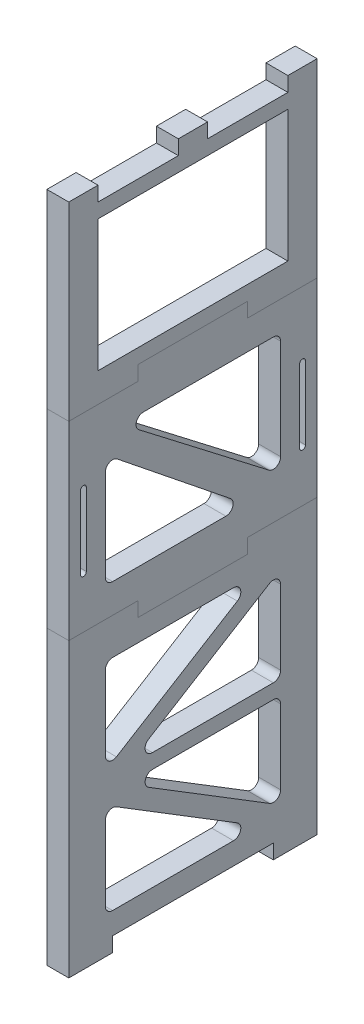
from build123d import *

# Parameters (mm, degrees)
SKETCH1_W                = 170
SKETCH1_H                = 410
BOSS_EXTRUDE1_DEPTH      = 15
SKETCH11_W               = 15
SKETCH11_H               = 30
BOSS_EXTRUDE8_DEPTH      = 10
SKETCH14_W               = 15
SKETCH14_H               = 170
BOSS_EXTRUDE9_DEPTH      = 30
SKETCH15_W               = 15
SKETCH15_H               = 20
BOSS_EXTRUDE10_DEPTH     = 10
SKETCH16_W               = 15
SKETCH16_H               = 20
BOSS_EXTRUDE11_DEPTH     = 10
CUT_EXTRUDE1_DEPTH       = 15
SKETCH25_W               = 130
SKETCH25_H               = 90
CUT_EXTRUDE3_DEPTH       = 15
CUT_EXTRUDE4_DEPTH       = 15
CUT_EXTRUDE5_DEPTH       = 15
SPLIT2_SURFACE_1_1_BACK  = 491.637
SPLIT2_SURFACE_1_1_DEPTH = 983.274
SPLIT2_SURFACE_1_2_BACK  = 491.637
SPLIT2_SURFACE_1_2_DEPTH = 983.274
SPLIT2_SURFACE_2_3_BACK  = 491.637
SPLIT2_SURFACE_2_3_DEPTH = 983.274
SPLIT2_SURFACE_2_4_BACK  = 491.637
SPLIT2_SURFACE_2_4_DEPTH = 983.274


with BuildPart() as part:
    # Sketch1 → Boss-Extrude1 (new body)
    with BuildSketch(Plane(origin=(0, 0, 0), x_dir=(0, 0, -1), z_dir=(1, 0, 0))):
        with Locations((85, 205)):
            Rectangle(SKETCH1_W, SKETCH1_H)
    extrude(amount=BOSS_EXTRUDE1_DEPTH)

    # Sketch11 → Boss-Extrude8 (add)
    with BuildSketch(Plane.XZ):
        with Locations((7.5, -15)):
            Rectangle(SKETCH11_W, SKETCH11_H)
        with Locations((7.5, -155)):
            Rectangle(SKETCH11_W, SKETCH11_H)
    extrude(amount=BOSS_EXTRUDE8_DEPTH)

    # Sketch14 → Boss-Extrude9 (add)
    with BuildSketch(Plane(origin=(0, 410, 0), x_dir=(1, 0, 0), z_dir=(0, 1, 0))):
        with Locations((7.5, 85)):
            Rectangle(SKETCH14_W, SKETCH14_H)
    extrude(amount=BOSS_EXTRUDE9_DEPTH)

    # Sketch15 → Boss-Extrude10 (add)
    with BuildSketch(Plane(origin=(0, 440, 0), x_dir=(1, 0, 0), z_dir=(0, 1, 0))):
        with Locations((7.5, 160)):
            Rectangle(SKETCH15_W, SKETCH15_H)
    boss_extrude10 = extrude(amount=BOSS_EXTRUDE10_DEPTH)

    # Mirror1: Boss-Extrude10 across plane
    add(boss_extrude10.mirror(Plane.XY.offset(-85)))

    # Sketch16 → Boss-Extrude11 (add)
    with BuildSketch(Plane(origin=(0, 440, 0), x_dir=(1, 0, 0), z_dir=(0, 1, 0))):
        with Locations((7.5, 85)):
            Rectangle(SKETCH16_W, SKETCH16_H)
    extrude(amount=BOSS_EXTRUDE11_DEPTH)

    # Sketch21 → Cut-Extrude1 (cut)
    with BuildSketch(Plane(origin=(15, 0, 0), x_dir=(0, 0, -1), z_dir=(1, 0, 0))):
        with BuildLine():
            Line((12, 275), (12, 225))
            ThreePointArc((12, 225), (10, 223), (8, 225))
            Line((8, 225), (8, 275))
            ThreePointArc((8, 275), (10, 277), (12, 275))
        make_face()
    cut_extrude1 = extrude(amount=-CUT_EXTRUDE1_DEPTH, mode=Mode.SUBTRACT)

    # Mirror3: Cut-Extrude1 across plane
    add(cut_extrude1.mirror(Plane.XY.offset(-85)), mode=Mode.SUBTRACT)

    # Sketch25 → Cut-Extrude3 (cut)
    with BuildSketch(Plane(origin=(15, 0, 0), x_dir=(0, 0, -1), z_dir=(1, 0, 0))):
        with Locations((85, 385)):
            Rectangle(SKETCH25_W, SKETCH25_H)
    extrude(amount=-CUT_EXTRUDE3_DEPTH, mode=Mode.SUBTRACT)

    # Sketch26 → Cut-Extrude4 (cut)
    with BuildSketch(Plane(origin=(15, 0, 0), x_dir=(0, 0, -1), z_dir=(1, 0, 0))):
        with BuildLine():
            Line((25, 70.930175943), (25, 20))
            ThreePointArc((25, 20), (26.464466094, 16.464466094), (30, 15))
            Line((30, 15), (112.761535907, 15))
            ThreePointArc((112.761535907, 15), (117.572536734, 18.638283788), (115.382023035, 24.258291584))
            Line((115.382023035, 24.258291584), (32.620487128, 75.188467526))
            ThreePointArc((32.620487128, 75.188467526), (27.560987458, 75.294946019), (25, 70.930175943))
        make_face()
        with BuildLine():
            Line((54.617976965, 75.741708416), (137.379512872, 24.811532474))
            ThreePointArc((137.379512872, 24.811532474), (142.439012542, 24.705053981), (145, 29.069824057))
            Line((145, 29.069824057), (145, 80))
            ThreePointArc((145, 80), (143.535533906, 83.535533906), (140, 85))
            Line((140, 85), (57.238464093, 85))
            ThreePointArc((57.238464093, 85), (52.427463266, 81.361716212), (54.617976965, 75.741708416))
        make_face()
        with BuildLine():
            Line((54.617976965, 104.258291584), (137.379512872, 155.188467526))
            ThreePointArc((137.379512872, 155.188467526), (142.439012542, 155.294946019), (145, 150.930175943))
            Line((145, 150.930175943), (145, 100))
            ThreePointArc((145, 100), (143.535533906, 96.464466094), (140, 95))
            Line((140, 95), (57.238464093, 95))
            ThreePointArc((57.238464093, 95), (52.427463266, 98.638283788), (54.617976965, 104.258291584))
        make_face()
        with BuildLine():
            Line((25, 160), (25, 109.069824057))
            ThreePointArc((25, 109.069824057), (27.560987458, 104.705053981), (32.620487128, 104.811532474))
            Line((32.620487128, 104.811532474), (115.382023035, 155.741708416))
            ThreePointArc((115.382023035, 155.741708416), (117.572536734, 161.361716212), (112.761535907, 165))
            Line((112.761535907, 165), (30, 165))
            ThreePointArc((30, 165), (26.464466094, 163.535533906), (25, 160))
        make_face()
    extrude(amount=-CUT_EXTRUDE4_DEPTH, mode=Mode.SUBTRACT)

    # Sketch24 → Cut-Extrude5 (cut)
    with BuildSketch(Plane(origin=(15, 0, 0), x_dir=(0, 0, -1), z_dir=(1, 0, 0))):
        with BuildLine():
            Line((47.992787609, 291.036880054), (136.951446196, 222.60714268))
            ThreePointArc((136.951446196, 222.60714268), (142.208758812, 222.084575999), (145, 226.570262626))
            Line((145, 226.570262626), (145, 295))
            ThreePointArc((145, 295), (143.535533906, 298.535533906), (140, 300))
            Line((140, 300), (51.041341414, 300))
            ThreePointArc((51.041341414, 300), (46.307653648, 296.610031098), (47.992787609, 291.036880054))
        make_face()
        with BuildLine():
            Line((25, 277.20619806), (25, 215))
            ThreePointArc((25, 215), (26.464466094, 211.464466094), (30, 210))
            Line((30, 210), (107.537666209, 210))
            ThreePointArc((107.537666209, 210), (112.254662185, 213.341702993), (110.666538333, 218.900020414))
            Line((110.666538333, 218.900020414), (33.128872124, 281.106218474))
            ThreePointArc((33.128872124, 281.106218474), (27.837173218, 281.71421096), (25, 277.20619806))
        make_face()
    extrude(amount=-CUT_EXTRUDE5_DEPTH, mode=Mode.SUBTRACT)


with BuildPart() as body_2:
    # Split2: the piece behind the surface
    add(part.part)
    # Split2 surface 1: a surface, the sketch's curves swept straight by 983.274 mm
    with BuildLine(Plane(origin=(15, 0, 0), x_dir=(0, 0, -1), z_dir=(1, 0, 0)).offset(-SPLIT2_SURFACE_1_1_BACK), mode=Mode.PRIVATE) as split2_surface_1_1_path:
        Line((170, 320), (122.5, 320))
        Line((122.5, 320), (122.5, 330))
        Line((122.5, 330), (47.5, 330))
        Line((47.5, 330), (47.5, 320))
        Line((47.5, 320), (0, 320))
    split2_surface_1_1 = Shell.extrude(split2_surface_1_1_path.wire(), (1 * SPLIT2_SURFACE_1_1_DEPTH, 0 * SPLIT2_SURFACE_1_1_DEPTH, 0 * SPLIT2_SURFACE_1_1_DEPTH))
    split(bisect_by=split2_surface_1_1, keep=Keep.BOTTOM)


with BuildPart() as part_1:
    add(part.part)

    # Split2: split by a surface, the side it looks to stays
    # Split2 surface 1: a surface, the sketch's curves swept straight by 983.274 mm
    with BuildLine(Plane(origin=(15, 0, 0), x_dir=(0, 0, -1), z_dir=(1, 0, 0)).offset(-SPLIT2_SURFACE_1_2_BACK), mode=Mode.PRIVATE) as split2_surface_1_2_path:
        Line((170, 320), (122.5, 320))
        Line((122.5, 320), (122.5, 330))
        Line((122.5, 330), (47.5, 330))
        Line((47.5, 330), (47.5, 320))
        Line((47.5, 320), (0, 320))
    split2_surface_1_2 = Shell.extrude(split2_surface_1_2_path.wire(), (1 * SPLIT2_SURFACE_1_2_DEPTH, 0 * SPLIT2_SURFACE_1_2_DEPTH, 0 * SPLIT2_SURFACE_1_2_DEPTH))
    split(bisect_by=split2_surface_1_2, keep=Keep.TOP)


with BuildPart() as body_3:
    # Split2 2: the piece behind the surface
    add(part_1.part)
    # Split2 surface 2: a surface, the sketch's curves swept straight by 983.274 mm
    with BuildLine(Plane(origin=(15, 0, 0), x_dir=(0, 0, -1), z_dir=(1, 0, 0)).offset(-SPLIT2_SURFACE_2_3_BACK), mode=Mode.PRIVATE) as split2_surface_2_3_path:
        Line((170, 190), (122.5, 190))
        Line((122.5, 190), (122.5, 180))
        Line((122.5, 180), (47.5, 180))
        Line((47.5, 180), (47.5, 190))
        Line((47.5, 190), (0, 190))
    split2_surface_2_3 = Shell.extrude(split2_surface_2_3_path.wire(), (1 * SPLIT2_SURFACE_2_3_DEPTH, 0 * SPLIT2_SURFACE_2_3_DEPTH, 0 * SPLIT2_SURFACE_2_3_DEPTH))
    split(bisect_by=split2_surface_2_3, keep=Keep.BOTTOM)


with BuildPart() as part_2:
    add(part_1.part)

    # Split2 2: split by a surface, the side it looks to stays
    # Split2 surface 2: a surface, the sketch's curves swept straight by 983.274 mm
    with BuildLine(Plane(origin=(15, 0, 0), x_dir=(0, 0, -1), z_dir=(1, 0, 0)).offset(-SPLIT2_SURFACE_2_4_BACK), mode=Mode.PRIVATE) as split2_surface_2_4_path:
        Line((170, 190), (122.5, 190))
        Line((122.5, 190), (122.5, 180))
        Line((122.5, 180), (47.5, 180))
        Line((47.5, 180), (47.5, 190))
        Line((47.5, 190), (0, 190))
    split2_surface_2_4 = Shell.extrude(split2_surface_2_4_path.wire(), (1 * SPLIT2_SURFACE_2_4_DEPTH, 0 * SPLIT2_SURFACE_2_4_DEPTH, 0 * SPLIT2_SURFACE_2_4_DEPTH))
    split(bisect_by=split2_surface_2_4, keep=Keep.TOP)


solid = Compound([body_2.part, body_3.part, part_2.part])
